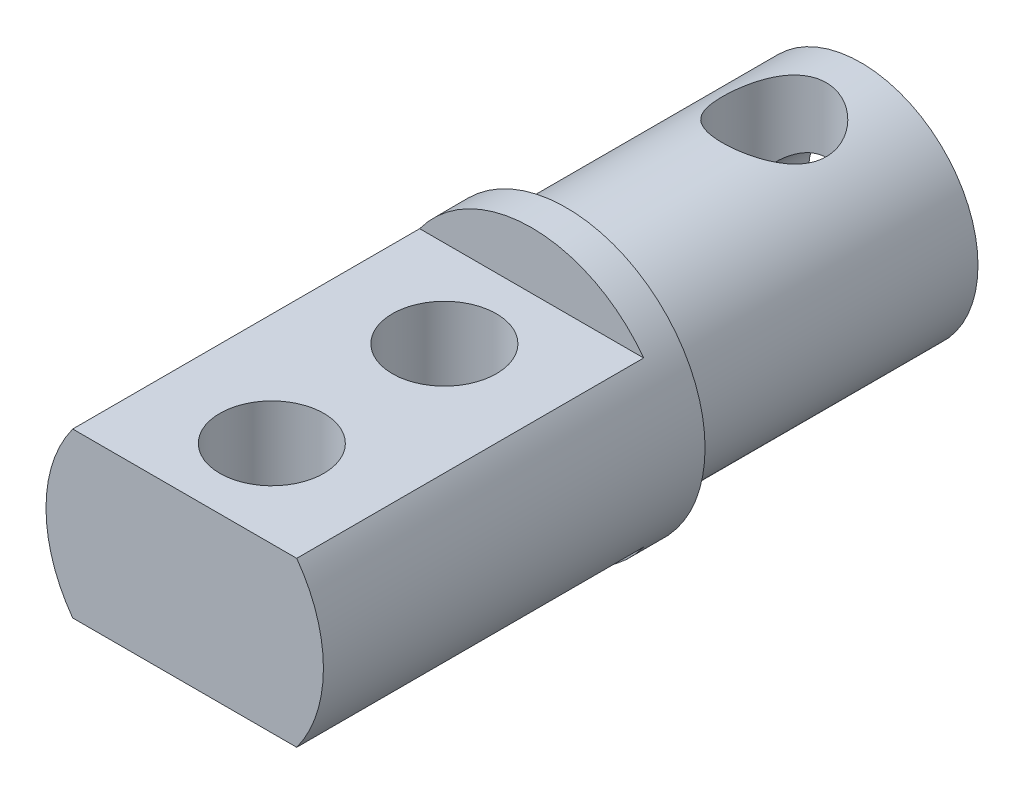
from build123d import *

# Parameters (mm, degrees)
SKETCH1_R               = 2.3876
EXTRUDE1_DEPTH          = 17.47
EXTRUDE2_DEPTH          = 1.5875
SKETCH1_4_R             = 2.3876
EXTRUDE3_DEPTH          = 13.487
CUT_EXTRUDE1_START      = -3.9624
SKETCH1_5_R             = 2.3876
CUT_EXTRUDE1_DEPTH      = 13.487
SKETCH2_R               = 2.3813
CUT_EXTRUDE2_DEPTH      = 13.487
CUT_EXTRUDE2_DEPTH_BACK = 13.487


with BuildPart() as part:
    # Sketch1 → Extrude1 (new body)
    with BuildSketch(Plane.XY):
        with BuildLine():
            Line((3.829692416, 3.7465), (-3.829692416, 3.7465))
            ThreePointArc((-3.829692416, 3.7465), (-5.3575, 0), (-3.829692416, -3.7465))
            Line((-3.829692416, -3.7465), (3.829692416, -3.7465))
            ThreePointArc((3.829692416, -3.7465), (4.960866022, -2.023021148), (5.3575, 0))
            ThreePointArc((5.3575, 0), (4.960866022, 2.023021148), (3.829692416, 3.7465))
        make_face()
        Circle(SKETCH1_R, mode=Mode.SUBTRACT)
        with BuildLine():
            Line((-3.829692416, 3.7465), (-5.127010606, 3.7465))
            ThreePointArc((-5.127010606, 3.7465), (-6.35, 0), (-5.127010606, -3.7465))
            Line((-5.127010606, -3.7465), (-3.829692416, -3.7465))
            ThreePointArc((-3.829692416, -3.7465), (-5.3575, 0), (-3.829692416, 3.7465))
        make_face()
        with BuildLine():
            ThreePointArc((6.35, 0), (6.036514613, 1.970530722), (5.127010606, 3.7465))
            Line((5.127010606, 3.7465), (3.829692416, 3.7465))
            ThreePointArc((3.829692416, 3.7465), (4.960866022, 2.023021148), (5.3575, 0))
            ThreePointArc((5.3575, 0), (4.960866022, -2.023021148), (3.829692416, -3.7465))
            Line((3.829692416, -3.7465), (5.127010606, -3.7465))
            ThreePointArc((5.127010606, -3.7465), (6.036514613, -1.970530722), (6.35, 0))
        make_face()
        with BuildLine():
            Line((-3.829692416, 3.7465), (-5.127010606, 3.7465))
            ThreePointArc((-5.127010606, 3.7465), (-6.35, 0), (-5.127010606, -3.7465))
            Line((-5.127010606, -3.7465), (-3.829692416, -3.7465))
            ThreePointArc((-3.829692416, -3.7465), (-5.3575, 0), (-3.829692416, 3.7465))
        make_face()
        with BuildLine():
            ThreePointArc((6.35, 0), (6.036514613, 1.970530722), (5.127010606, 3.7465))
            Line((5.127010606, 3.7465), (3.829692416, 3.7465))
            ThreePointArc((3.829692416, 3.7465), (4.960866022, 2.023021148), (5.3575, 0))
            ThreePointArc((5.3575, 0), (4.960866022, -2.023021148), (3.829692416, -3.7465))
            Line((3.829692416, -3.7465), (5.127010606, -3.7465))
            ThreePointArc((5.127010606, -3.7465), (6.036514613, -1.970530722), (6.35, 0))
        make_face()
        Circle(SKETCH1_R)
    extrude(amount=EXTRUDE1_DEPTH)

    # Sketch1_3 → Extrude2 (add)
    with BuildSketch(Plane.XY):
        with BuildLine():
            ThreePointArc((5.127010606, 3.7465), (0, 6.35), (-5.127010606, 3.7465))
            Line((-5.127010606, 3.7465), (-3.829692416, 3.7465))
            ThreePointArc((-3.829692416, 3.7465), (0, 5.3575), (3.829692416, 3.7465))
            Line((3.829692416, 3.7465), (5.127010606, 3.7465))
        make_face()
        with BuildLine():
            ThreePointArc((3.829692416, 3.7465), (0, 5.3575), (-3.829692416, 3.7465))
            Line((-3.829692416, 3.7465), (3.829692416, 3.7465))
        make_face()
        with BuildLine():
            Line((-3.829692416, -3.7465), (-5.127010606, -3.7465))
            ThreePointArc((-5.127010606, -3.7465), (0, -6.35), (5.127010606, -3.7465))
            Line((5.127010606, -3.7465), (3.829692416, -3.7465))
            ThreePointArc((3.829692416, -3.7465), (0, -5.3575), (-3.829692416, -3.7465))
        make_face()
        with BuildLine():
            Line((3.829692416, -3.7465), (-3.829692416, -3.7465))
            ThreePointArc((-3.829692416, -3.7465), (0, -5.3575), (3.829692416, -3.7465))
        make_face()
    extrude(amount=EXTRUDE2_DEPTH)

    # Sketch1_4 → Extrude3 (add)
    with BuildSketch(Plane.XY):
        with BuildLine():
            Line((3.829692416, 3.7465), (-3.829692416, 3.7465))
            ThreePointArc((-3.829692416, 3.7465), (-5.3575, 0), (-3.829692416, -3.7465))
            Line((-3.829692416, -3.7465), (3.829692416, -3.7465))
            ThreePointArc((3.829692416, -3.7465), (4.960866022, -2.023021148), (5.3575, 0))
            ThreePointArc((5.3575, 0), (4.960866022, 2.023021148), (3.829692416, 3.7465))
        make_face()
        Circle(SKETCH1_4_R, mode=Mode.SUBTRACT)
        Circle(SKETCH1_4_R)
        with BuildLine():
            Line((3.829692416, -3.7465), (-3.829692416, -3.7465))
            ThreePointArc((-3.829692416, -3.7465), (0, -5.3575), (3.829692416, -3.7465))
        make_face()
        with BuildLine():
            ThreePointArc((3.829692416, 3.7465), (0, 5.3575), (-3.829692416, 3.7465))
            Line((-3.829692416, 3.7465), (3.829692416, 3.7465))
        make_face()
    extrude(amount=-EXTRUDE3_DEPTH)

    # Sketch1_5 → Cut-Extrude1 (cut)
    with BuildSketch(Plane.XY.offset(CUT_EXTRUDE1_START)):
        Circle(SKETCH1_5_R)
    extrude(amount=-CUT_EXTRUDE1_DEPTH, mode=Mode.SUBTRACT)

    # Sketch2 → Cut-Extrude2 (cut, two sides)
    with BuildSketch(Plane(origin=(0, 0, 0), x_dir=(1, 0, 0), z_dir=(0, 1, 0))) as cut_extrude2_sk:
        with Locations(Location((0, -5.5828, 0), (0, 0, 270))):  # turned: the seam where the file's is
            Circle(SKETCH2_R)
        with Locations(Location((0, -13.4822, 0), (0, 0, 270))):  # turned: the seam where the file's is
            Circle(SKETCH2_R)
        with Locations(Location((0, 9.5175, 0), (0, 0, 270))):  # turned: the seam where the file's is
            Circle(SKETCH2_R)
    extrude(amount=CUT_EXTRUDE2_DEPTH, mode=Mode.SUBTRACT)
    extrude(cut_extrude2_sk.sketch, amount=-CUT_EXTRUDE2_DEPTH_BACK, mode=Mode.SUBTRACT)


solid = part.part
